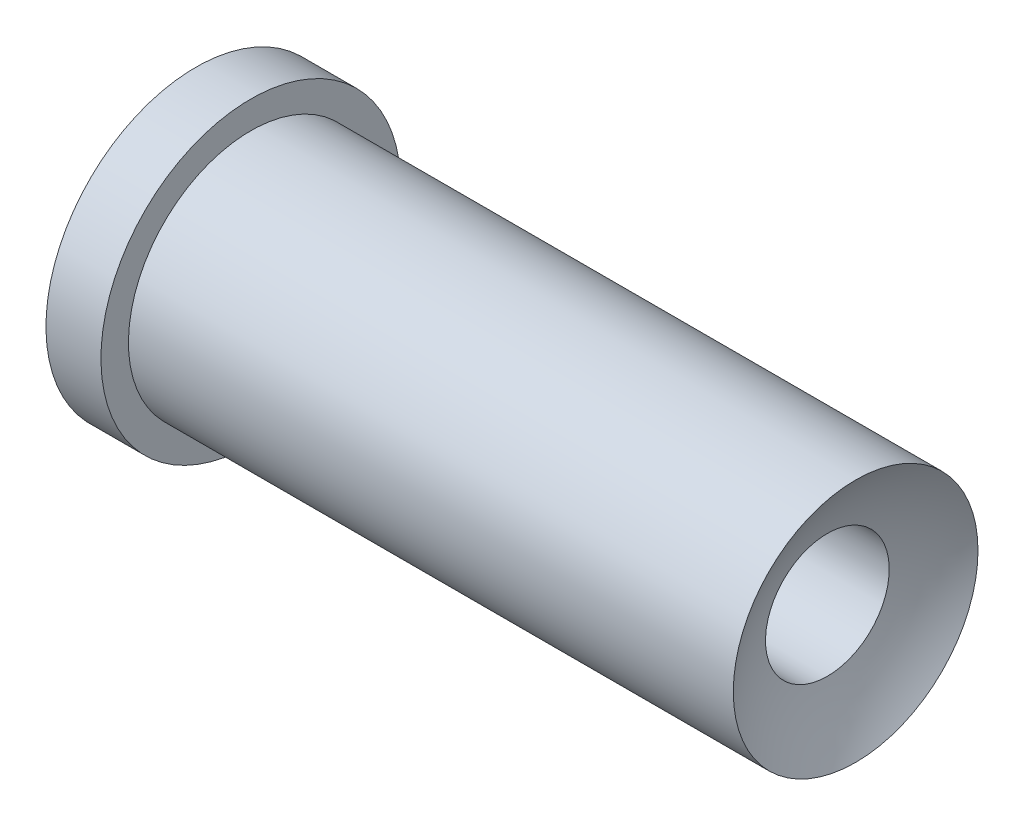
from build123d import *


with BuildPart() as part:
    # Sketch1 → Revolve1 (revolve)
    with BuildSketch(Plane.XY):
        Polygon((-120, 0), (120, 0), (120, 44.5), (-100, 44.5), (-100, 54.5), (-120, 54.5), align=None)
    revolve(axis=Axis((-120, 0, 0), (1, 0, 0)))

    # Sketch2 → Cut-Revolve2 (revolve, cut)
    with BuildSketch(Plane.XY):
        with BuildLine():
            Line((66.48120035, 0), (266.48120035, 0))
            ThreePointArc((266.48120035, 0), (197.846476125, 79.188575606), (109.710437686, 22.5))
            Line((109.710437686, 22.5), (66.48120035, 22.5))
            Line((66.48120035, 22.5), (66.48120035, 0))
        make_face()
    revolve(axis=Axis((66.48120035, 0, 0), (1, 0, 0)), mode=Mode.SUBTRACT)


solid = part.part
